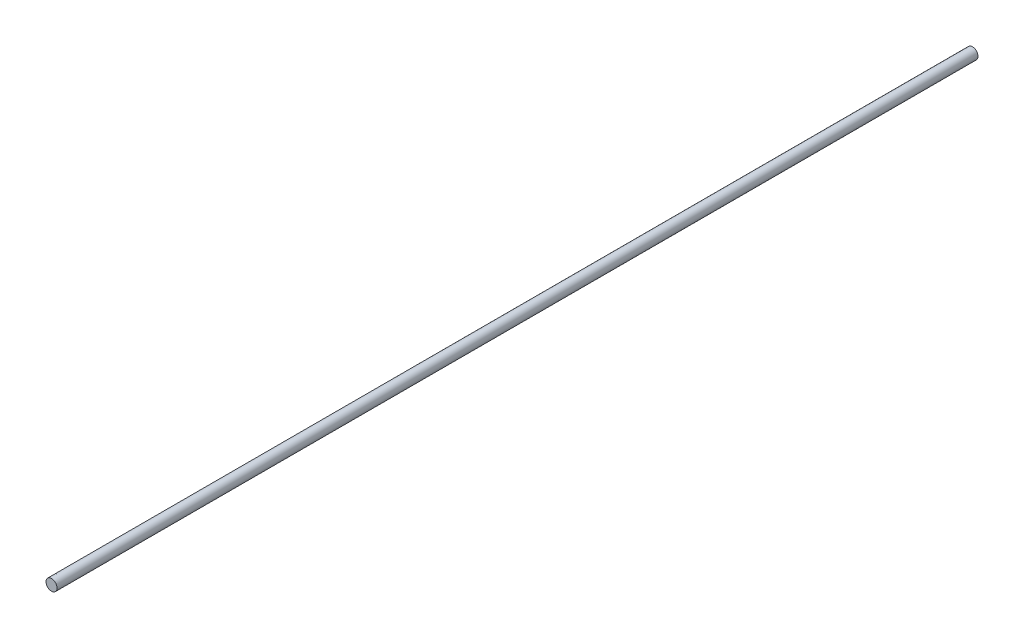
from build123d import *

# Parameters (mm, degrees)
SKETCH1_R           = 6
BOSS_EXTRUDE2_DEPTH = 1000


with BuildPart() as part:
    # Sketch1 → Boss-Extrude2 (new body)
    with BuildSketch(Plane.XY):
        Circle(SKETCH1_R)
    extrude(amount=BOSS_EXTRUDE2_DEPTH)


solid = part.part
